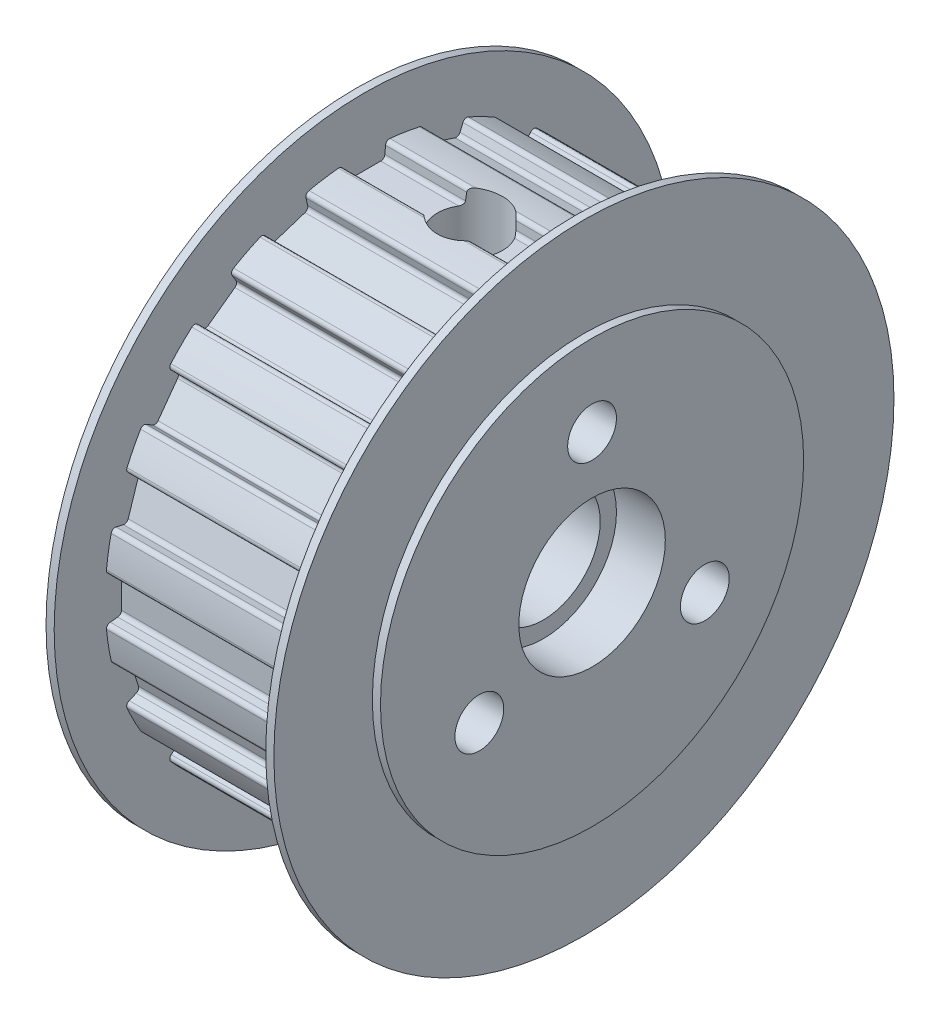
from build123d import *

# Parameters (mm, degrees)
ESQUISSE1_R                         = 15.915
EXTRUSION1_DEPTH                    = 13
ENL_V_MAT_EXTRU_2_DEPTH             = 13
CONG_1_R                            = 0.25
CONG_2_R                            = 0.25
CONG_3_R                            = 0.25
CONG_4_R                            = 0.25
R_P_TITION_CIRCULAIRE1_COUNT        = 20
CONG_1_OF_R_P_TITION_CIRCULAIRE1_R  = 0.25
CONG_2_OF_R_P_TITION_CIRCULAIRE1_R  = 0.25
CONG_3_OF_R_P_TITION_CIRCULAIRE1_R  = 0.25
CONG_4_OF_R_P_TITION_CIRCULAIRE1_R  = 0.25
ESQUISSE23_R                        = 19.05
EXTRUSION2_DEPTH                    = 1
ESQUISSE24_R                        = 19.05
EXTRUSION3_DEPTH                    = 1
ESQUISSE25_R                        = 3.5
ESQUISSE25_R_2                      = 1.5
ENL_V_MAT_EXTRU_3_DEPTH             = 16
ENL_V_MAT_EXTRU_5_REACH             = 35.965
ESQUISSE30_R                        = 2
ENL_V_MAT_EXTRU_5_DIRECTION_2_DEPTH = 5.135
ESQUISSE31_OUTSIDE_W                = 51.286
ESQUISSE31_OUTSIDE_H                = 51.286
ESQUISSE31_OUTSIDE_R                = 13
ENL_V_MAT_EXTRU_6_DEPTH             = 0.5
ESQUISSE32_OUTSIDE_W                = 51.286
ESQUISSE32_OUTSIDE_H                = 51.286
ESQUISSE32_OUTSIDE_R                = 13
ENL_V_MAT_EXTRU_7_DEPTH             = 0.5
CHANFREIN1_SIZE                     = 0.25
CHANFREIN2_SIZE                     = 0.25
ESQUISSE33_R                        = 4.5
EXTRUSION4_DEPTH                    = 3
CHANFREIN3_SIZE                     = 1.25


with BuildPart() as part:
    # Esquisse1 → Extrusion1 (new body)
    with BuildSketch(Plane(origin=(0, 0, 0), x_dir=(0, 0, -1), z_dir=(1, 0, 0))):
        Circle(ESQUISSE1_R)
    extrude(amount=EXTRUSION1_DEPTH)

    # Esquisse22 → Enlèv. mat.-Extru.2 (cut)
    with BuildSketch(Plane.ZY):
        Polygon((-1.25, 14.915), (1.25, 14.915), (2.12662356, 25.374872317), (-2.12713714, 25.381000349), align=None)
    enl_v_mat_extru_2 = extrude(amount=-ENL_V_MAT_EXTRU_2_DEPTH, mode=Mode.SUBTRACT)

    # Congé1
    cong_1_edges = [part.edges().sort_by_distance(p)[0] for p in [
        (6.5, 14.915, -1.25),
    ]]
    fillet(cong_1_edges, radius=CONG_1_R)

    # Congé2
    cong_2_edges = [part.edges().sort_by_distance(p)[0] for p in [
        (6.5, 15.859400654, -1.329148563),
    ]]
    fillet(cong_2_edges, radius=CONG_2_R)

    # Congé3
    cong_3_edges = [part.edges().sort_by_distance(p)[0] for p in [
        (6.5, 14.915, 1.25),
    ]]
    fillet(cong_3_edges, radius=CONG_3_R)

    # Congé4
    cong_4_edges = [part.edges().sort_by_distance(p)[0] for p in [
        (6.5, 15.859400654, 1.329148563),
    ]]
    fillet(cong_4_edges, radius=CONG_4_R)

    # Répétition circulaire1: Enlèv. mat.-Extru.2 ×20 about axis
    r_p_tition_circulaire1_axis = Axis((0, 0, 0), (1, 0, 0))
    for i in range(1, R_P_TITION_CIRCULAIRE1_COUNT):
        add(enl_v_mat_extru_2.rotate(r_p_tition_circulaire1_axis, i * 360 / R_P_TITION_CIRCULAIRE1_COUNT), mode=Mode.SUBTRACT)

    # Congé1 of Répétition circulaire1
    cong_1_of_r_p_tition_circulaire1_edges = [part.edges().sort_by_distance(p)[0] for p in [
        (6.5, 14.571279184, 3.420167826),
        (6.5, 12.801220036, 7.755545795),
        (6.5, 9.778088281, 11.331756906),
        (6.5, 5.797809116, 13.798736698),
        (6.5, 1.25, 14.915),
        (6.5, -3.420167826, 14.571279184),
        (6.5, -7.755545795, 12.801220036),
        (6.5, -11.331756906, 9.778088281),
        (6.5, -13.798736698, 5.797809116),
        (6.5, -14.915, 1.25),
        (6.5, -14.571279184, -3.420167826),
        (6.5, -12.801220036, -7.755545795),
        (6.5, -9.778088281, -11.331756906),
        (6.5, -5.797809116, -13.798736698),
        (6.5, -1.25, -14.915),
        (6.5, 3.420167826, -14.571279184),
        (6.5, 7.755545795, -12.801220036),
        (6.5, 11.331756906, -9.778088281),
        (6.5, 13.798736698, -5.797809116),
    ]]
    fillet(cong_1_of_r_p_tition_circulaire1_edges, radius=CONG_1_OF_R_P_TITION_CIRCULAIRE1_R)

    # Congé2 of Répétition circulaire1
    cong_2_of_r_p_tition_circulaire1_edges = [part.edges().sort_by_distance(p)[0] for p in [
        (6.5, 15.49391583, 3.636728921),
        (6.5, 13.611778573, 8.246618039),
        (6.5, 10.39722559, 12.049270726),
        (6.5, 6.164919725, 14.672456842),
        (6.5, 1.329148563, 15.859400654),
        (6.5, -3.636728921, 15.49391583),
        (6.5, -8.246618039, 13.611778573),
        (6.5, -12.049270726, 10.39722559),
        (6.5, -14.672456842, 6.164919725),
        (6.5, -15.859400654, 1.329148563),
        (6.5, -15.49391583, -3.636728921),
        (6.5, -13.611778573, -8.246618039),
        (6.5, -10.39722559, -12.049270726),
        (6.5, -6.164919725, -14.672456842),
        (6.5, -1.329148563, -15.859400654),
        (6.5, 3.636728921, -15.49391583),
        (6.5, 8.246618039, -13.611778573),
        (6.5, 12.049270726, -10.39722559),
        (6.5, 14.672456842, -6.164919725),
    ]]
    fillet(cong_2_of_r_p_tition_circulaire1_edges, radius=CONG_2_OF_R_P_TITION_CIRCULAIRE1_R)

    # Congé3 of Répétition circulaire1
    cong_3_of_r_p_tition_circulaire1_edges = [part.edges().sort_by_distance(p)[0] for p in [
        (6.5, 13.798736698, 5.797809116),
        (6.5, 11.331756906, 9.778088281),
        (6.5, 7.755545795, 12.801220036),
        (6.5, 3.420167826, 14.571279184),
        (6.5, -1.25, 14.915),
        (6.5, -5.797809116, 13.798736698),
        (6.5, -9.778088281, 11.331756906),
        (6.5, -12.801220036, 7.755545795),
        (6.5, -14.571279184, 3.420167826),
        (6.5, -14.915, -1.25),
        (6.5, -13.798736698, -5.797809116),
        (6.5, -11.331756906, -9.778088281),
        (6.5, -7.755545795, -12.801220036),
        (6.5, -3.420167826, -14.571279184),
        (6.5, 1.25, -14.915),
        (6.5, 5.797809116, -13.798736698),
        (6.5, 9.778088281, -11.331756906),
        (6.5, 12.801220036, -7.755545795),
        (6.5, 14.571279184, -3.420167826),
    ]]
    fillet(cong_3_of_r_p_tition_circulaire1_edges, radius=CONG_3_OF_R_P_TITION_CIRCULAIRE1_R)

    # Congé4 of Répétition circulaire1
    cong_4_of_r_p_tition_circulaire1_edges = [part.edges().sort_by_distance(p)[0] for p in [
        (6.5, 14.672456842, 6.164919725),
        (6.5, 12.049270726, 10.39722559),
        (6.5, 8.246618039, 13.611778573),
        (6.5, 3.636728921, 15.49391583),
        (6.5, -1.329148563, 15.859400654),
        (6.5, -6.164919725, 14.672456842),
        (6.5, -10.39722559, 12.049270726),
        (6.5, -13.611778573, 8.246618039),
        (6.5, -15.49391583, 3.636728921),
        (6.5, -15.859400654, -1.329148563),
        (6.5, -14.672456842, -6.164919725),
        (6.5, -12.049270726, -10.39722559),
        (6.5, -8.246618039, -13.611778573),
        (6.5, -3.636728921, -15.49391583),
        (6.5, 1.329148563, -15.859400654),
        (6.5, 6.164919725, -14.672456842),
        (6.5, 10.39722559, -12.049270726),
        (6.5, 13.611778573, -8.246618039),
        (6.5, 15.49391583, -3.636728921),
    ]]
    fillet(cong_4_of_r_p_tition_circulaire1_edges, radius=CONG_4_OF_R_P_TITION_CIRCULAIRE1_R)

    # Esquisse23 → Extrusion2 (add)
    with BuildSketch(Plane.ZY):
        Circle(ESQUISSE23_R)
    extrude(amount=EXTRUSION2_DEPTH)

    # Esquisse24 → Extrusion3 (add)
    with BuildSketch(Plane(origin=(13, 0, 0), x_dir=(0, 0, -1), z_dir=(1, 0, 0))):
        Circle(ESQUISSE24_R)
    extrude(amount=EXTRUSION3_DEPTH)

    # Esquisse25 → Enlèv. mat.-Extru.3 (cut, through all)
    with BuildSketch(Plane.ZY.offset(1)):
        Circle(ESQUISSE25_R)
        with Locations((0, 8)):
            Circle(ESQUISSE25_R_2)
        with Locations((6.92820323, -4)):
            Circle(ESQUISSE25_R_2)
        with Locations((-6.92820323, -4)):
            Circle(ESQUISSE25_R_2)
    extrude(amount=-ENL_V_MAT_EXTRU_3_DEPTH, mode=Mode.SUBTRACT)

    # Esquisse30 → Enlèv. mat.-Extru.5 (cut, up to next)
    with BuildSketch(Plane(origin=(0, 14.915, 0), x_dir=(-1, 0, 0), z_dir=(0, 1, 0)), mode=Mode.PRIVATE) as enl_v_mat_extru_5_sk1:
        with Locations((-6.5, 0)):
            Circle(ESQUISSE30_R)
    enl_v_mat_extru_5_tool1 = extrude(enl_v_mat_extru_5_sk1.sketch, amount=-ENL_V_MAT_EXTRU_5_REACH, mode=Mode.PRIVATE) & part.part
    add(enl_v_mat_extru_5_tool1.solids().sort_by_distance((6.5, 14.915, 0))[0], mode=Mode.SUBTRACT)

    # Esquisse30 → Enlèv. mat.-Extru.5 direction 2 (cut)
    with BuildSketch(Plane(origin=(0, 14.915, 0), x_dir=(-1, 0, 0), z_dir=(0, 1, 0))):
        with Locations((-6.5, 0)):
            Circle(ESQUISSE30_R)
    extrude(amount=ENL_V_MAT_EXTRU_5_DIRECTION_2_DEPTH, mode=Mode.SUBTRACT)

    # Esquisse31 outside → Enlèv. mat.-Extru.6 (cut)
    with BuildSketch(Plane.ZY.offset(1)):
        Rectangle(ESQUISSE31_OUTSIDE_W, ESQUISSE31_OUTSIDE_H)
        Circle(ESQUISSE31_OUTSIDE_R, mode=Mode.SUBTRACT)
    extrude(amount=-ENL_V_MAT_EXTRU_6_DEPTH, mode=Mode.SUBTRACT)

    # Esquisse32 outside → Enlèv. mat.-Extru.7 (cut)
    with BuildSketch(Plane(origin=(14, 0, 0), x_dir=(0, 0, -1), z_dir=(1, 0, 0))):
        Rectangle(ESQUISSE32_OUTSIDE_W, ESQUISSE32_OUTSIDE_H)
        Circle(ESQUISSE32_OUTSIDE_R, mode=Mode.SUBTRACT)
    extrude(amount=-ENL_V_MAT_EXTRU_7_DEPTH, mode=Mode.SUBTRACT)

    # Chanfrein1
    chanfrein1_edges = [part.edges().sort_by_distance(p)[0] for p in [
        (14, 0, -3.5),
    ]]
    chamfer(chanfrein1_edges, length=CHANFREIN1_SIZE)

    # Chanfrein2
    chanfrein2_edges = [part.edges().sort_by_distance(p)[0] for p in [
        (-1, 0, -3.5),
    ]]
    chamfer(chanfrein2_edges, length=CHANFREIN2_SIZE)

    # Esquisse33 → Extrusion4 (cut)
    with BuildSketch(Plane(origin=(14, 0, 0), x_dir=(0, 0, -1), z_dir=(1, 0, 0))):
        Circle(ESQUISSE33_R)
    extrude(amount=-EXTRUSION4_DEPTH, mode=Mode.SUBTRACT)

    # Chanfrein3
    chanfrein3_edges = [part.edges().sort_by_distance(p)[0] for p in [
        (-1, 8, -1.5),
        (-1, -4, 5.42820323),
        (-1, -4, -8.42820323),
    ]]
    chamfer(chanfrein3_edges, length=CHANFREIN3_SIZE)


solid = part.part
